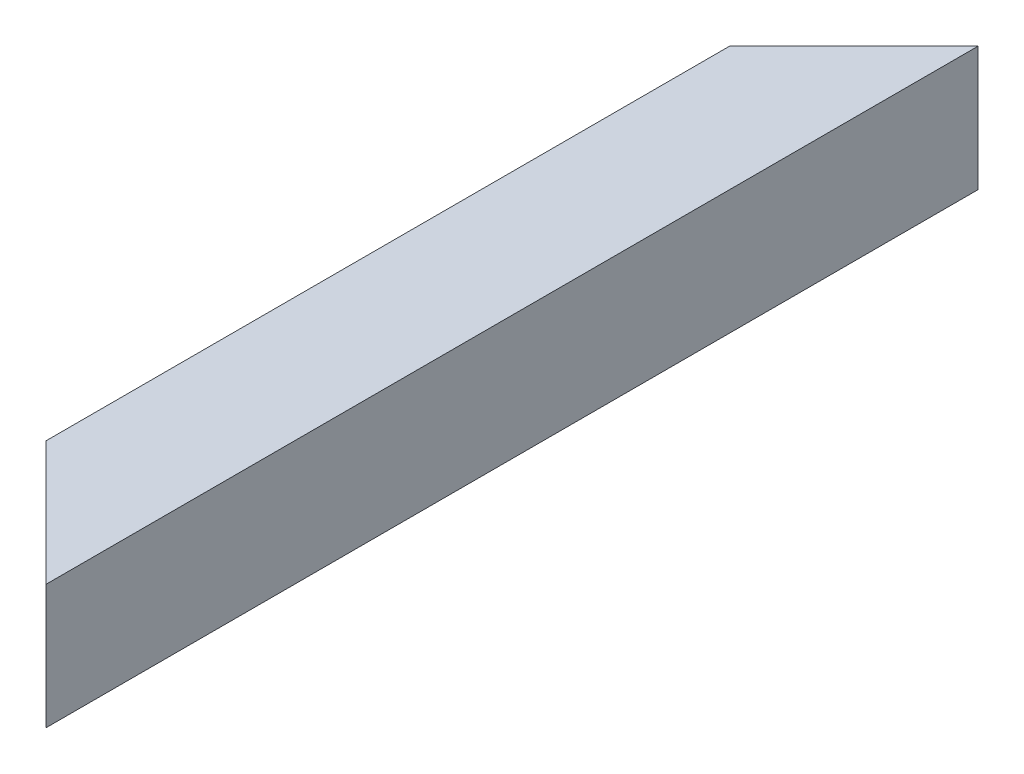
from build123d import *

# Parameters (mm, degrees)
SKETCH1_W          = 40
SKETCH1_H          = 40
SKETCH1_W_2        = 32
SKETCH1_H_2        = 32
CUT_EXTRUDE1_DEPTH = 41.0000001


with BuildPart() as part:
    # Sweep1: sweep along a curve in space
    with BuildLine() as sweep1_path:
        add(Edge.make_bspline(
            [(0, 0, 0), (0, 0, 300)],
            knots=[0, 0, 1, 1], degree=1))
    # Sketch1 → Sweep1 (sweep)
    with BuildSketch(Plane.XY):
        Rectangle(SKETCH1_W, SKETCH1_H)
        Rectangle(SKETCH1_W_2, SKETCH1_H_2, mode=Mode.SUBTRACT)
    sweep(path=sweep1_path.line)

    # Sketch2 → Cut-Extrude1 (cut, through all)
    with BuildSketch(Plane(origin=(0, 20, 0), x_dir=(1, 0, 0), z_dir=(0, 1, 0))):
        Polygon((20, 0), (-20, -40), (-20, 0), align=None)
        Polygon((20, -300), (-20, -260), (-20, -300), align=None)
    extrude(amount=-CUT_EXTRUDE1_DEPTH, mode=Mode.SUBTRACT)


solid = part.part
